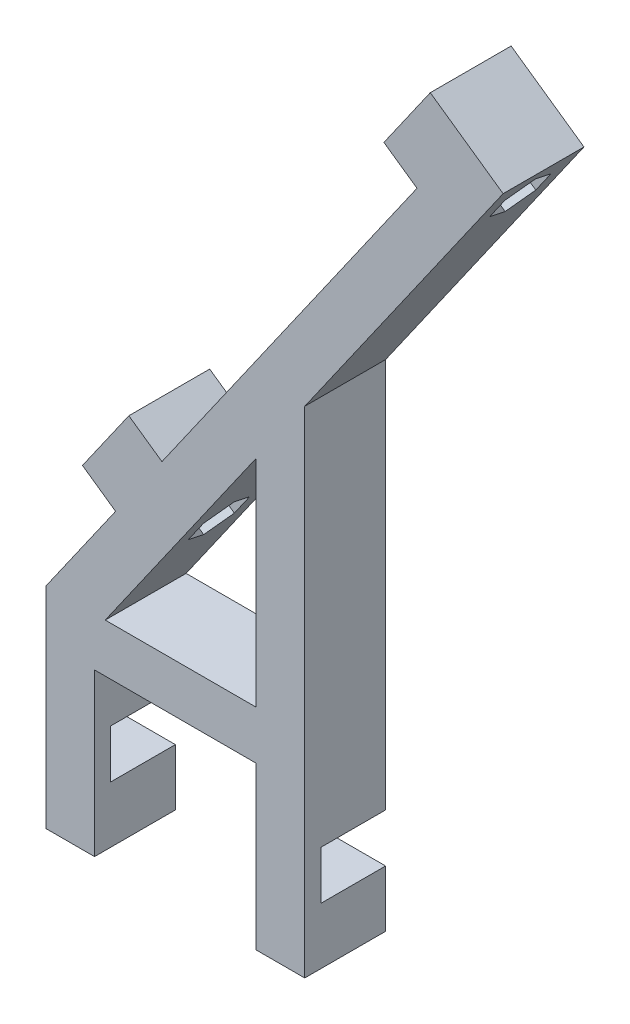
from build123d import *

# Parameters (mm, degrees)
RESSALTO_EXTRUS_O1_DEPTH   = 10
ESBO_O3_W                  = 8
ESBO_O3_H                  = 6
CORTE_EXTRUS_O2_DEPTH      = 1
CORTE_EXTRUS_O2_DEPTH_BACK = 57.536791537
CORTE_EXTRUS_O1_REACH      = 63.225
ESBO_O2_R                  = 1.7
ESBO_O6_W                  = 10
ESBO_O6_H                  = 10
ESBO_O6_R                  = 1.7
RESSALTO_EXTRUS_O2_DEPTH   = 5
CORTE_EXTRUS_O5_DEPTH      = 4


with BuildPart() as part:
    # Esboço1 → Ressalto-extrusão1 (new body)
    with BuildSketch(Plane.XY):
        Polygon((0, 0), (0, -26), (6, -26), (6, -6), (26, -6), (26, -26), (32, -26), (32, 35.240055442), (56.536791537, 70.282225368), (51.621879272, 73.723683986), align=None)
        Polygon((26, 0), (26, 26.671167402), (7.324647533, 0), align=None, mode=Mode.SUBTRACT)
    extrude(amount=RESSALTO_EXTRUS_O1_DEPTH)

    # Esboço3 → Corte-extrusão2 (cut, two sides)
    with BuildSketch(Plane.ZY) as corte_extrus_o2_sk:
        with Locations((4, -16)):
            Rectangle(ESBO_O3_W, ESBO_O3_H)
    extrude(amount=CORTE_EXTRUS_O2_DEPTH, mode=Mode.SUBTRACT)
    extrude(corte_extrus_o2_sk.sketch, amount=-CORTE_EXTRUS_O2_DEPTH_BACK, mode=Mode.SUBTRACT)

    # Esboço2 → Corte-extrusão1 (cut, up to next)
    with BuildSketch(Plane(origin=(0, 0, 0), x_dir=(0, 0, 1), z_dir=(-0.819152044, 0.573576436, 0)), mode=Mode.PRIVATE) as corte_extrus_o1_sk1:
        with Locations((5, 85)):
            Circle(ESBO_O2_R)
    corte_extrus_o1_tool1 = extrude(corte_extrus_o1_sk1.sketch, amount=-CORTE_EXTRUS_O1_REACH, mode=Mode.PRIVATE) & part.part
    add(corte_extrus_o1_tool1.solids().sort_by_distance((48.753997, 69.627924, 5))[0], mode=Mode.SUBTRACT)
    # Esboço2 → Corte-extrusão1 (cut, up to next)
    with BuildSketch(Plane(origin=(0, 0, 0), x_dir=(0, 0, 1), z_dir=(-0.819152044, 0.573576436, 0)), mode=Mode.PRIVATE) as corte_extrus_o1_sk2:
        with Locations((5, 20)):
            Circle(ESBO_O2_R)
    corte_extrus_o1_tool2 = extrude(corte_extrus_o1_sk2.sketch, amount=-CORTE_EXTRUS_O1_REACH, mode=Mode.PRIVATE) & part.part
    add(corte_extrus_o1_tool2.solids().sort_by_distance((11.471529, 16.383041, 5))[0], mode=Mode.SUBTRACT)

    # Esboço6 → Ressalto-extrusão2 (add)
    with BuildSketch(Plane(origin=(0, 0, 0), x_dir=(0, 0, 1), z_dir=(-0.819152044, 0.573576436, 0))):
        with Locations((5, 85)):
            Rectangle(ESBO_O6_W, ESBO_O6_H)
        with Locations((5, 85)):
            Circle(ESBO_O6_R, mode=Mode.SUBTRACT)
        with Locations((5, 20)):
            Rectangle(ESBO_O6_W, ESBO_O6_H)
        with Locations((5, 20)):
            Circle(ESBO_O6_R, mode=Mode.SUBTRACT)
    extrude(amount=RESSALTO_EXTRUS_O2_DEPTH)

    # Esboço7 → Corte-extrusão5 (cut)
    with BuildSketch(Plane(origin=(4.914912266, -3.441458618, 0), x_dir=(0, 0, -1), z_dir=(0.819152044, -0.573576436, 0))):
        Polygon((-2.15, 83.354551733), (-2.15, 86.645448267), (-5, 88.290896534), (-7.85, 86.645448267), (-7.85, 83.354551733), (-5, 81.709103466), align=None)
        Polygon((-2.15, 18.354551733), (-2.15, 21.645448267), (-5, 23.290896534), (-7.85, 21.645448267), (-7.85, 18.354551733), (-5, 16.709103466), align=None)
    extrude(amount=-CORTE_EXTRUS_O5_DEPTH, mode=Mode.SUBTRACT)


solid = part.part
